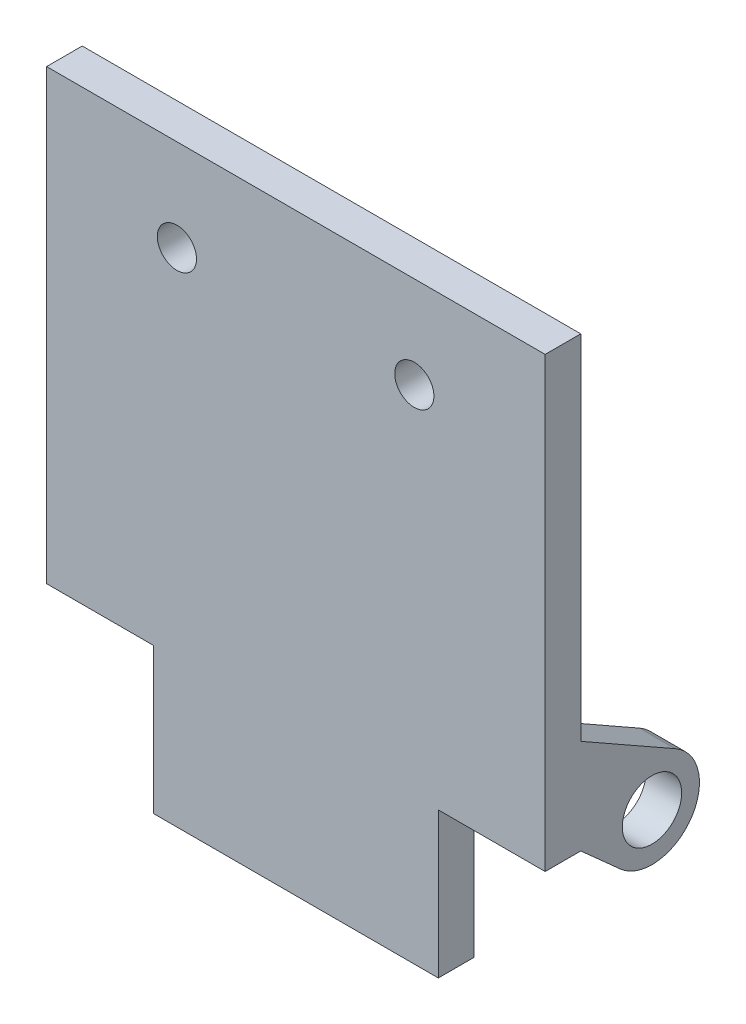
from build123d import *

# Parameters (mm, degrees)
SKETCH_1_W          = 42
SKETCH_1_H          = 50
EXTRUDE_1_DEPTH     = 3
SKETCH_3_W          = 3
SKETCH_3_H          = 5
SKETCH_3_H_2        = 10
EXTRUDE_2_DEPTH     = 12
FILLET_1_R          = 5
FILLET_2_R          = 5
SKETCH_4_R          = 1
CUT_EXTRUDE_1_DEPTH = 27
SKETCH_5_R          = 2.5
EXTRUDE_3_DEPTH     = 3
SKETCH_6_W          = 9
SKETCH_6_H          = 12.266046359
CUT_EXTRUDE_2_DEPTH = 4
SKETCH_7_R          = 1.65
CUT_EXTRUDE_3_DEPTH = 16
FILLET_3_R          = 3


with BuildPart() as part:
    # 草图1 → 凸台-拉伸1 (new body)
    with BuildSketch(Plane.XY):
        Rectangle(SKETCH_1_W, SKETCH_1_H)
    extrude(amount=EXTRUDE_1_DEPTH)

    # 草图3 → 凸台-拉伸2 (add)
    with BuildSketch(Plane(origin=(0, 0, 0), x_dir=(-1, 0, 0), z_dir=(0, 0, -1))):
        with Locations((3.5, -22.5)):
            Rectangle(SKETCH_3_W, SKETCH_3_H)
        with Locations((3.5, 8)):
            Rectangle(SKETCH_3_W, SKETCH_3_H_2)
    extrude(amount=EXTRUDE_2_DEPTH)

    # 圆角1
    fillet_1_edges = [part.edges().sort_by_distance(p)[0] for p in [
        (-2, 8, 0),
    ]]
    fillet(fillet_1_edges, radius=FILLET_1_R)

    # 圆角2
    fillet_2_edges = [part.edges().sort_by_distance(p)[0] for p in [
        (-2, -22.5, 0),
    ]]
    fillet(fillet_2_edges, radius=FILLET_2_R)

    # 草图4 → 切除-拉伸1 (cut, through all)
    with BuildSketch(Plane.ZY.offset(5)):
        with Locations((-5.946968178, -22)):
            Circle(SKETCH_4_R)
        with Locations((-5.946968178, 5)):
            Circle(SKETCH_4_R)
    extrude(amount=-CUT_EXTRUDE_1_DEPTH, mode=Mode.SUBTRACT)

    # 草图5 → 凸台-拉伸3 (add)
    with BuildSketch(Plane(origin=(21, 0, 0), x_dir=(0, 0, -1), z_dir=(1, 0, 0))):
        with BuildLine():
            Line((0, -4.733953641), (0, -12.733953641))
            Line((0, -12.733953641), (3.333333333, -15.715377611))
            ThreePointArc((3.333333333, -15.715377611), (9.249103106, -15.067047939), (7.972848445, -9.254317307))
            Line((7.972848445, -9.254317307), (0, -4.733953641))
        make_face()
        with Locations((6, -12.733953641)):
            Circle(SKETCH_5_R, mode=Mode.SUBTRACT)
    extrude(amount=-EXTRUDE_3_DEPTH)

    # 草图6 → 切除-拉伸2 (cut, through all)
    with BuildSketch(Plane(origin=(0, 0, 0), x_dir=(-1, 0, 0), z_dir=(0, 0, -1))):
        with Locations((-16.5, -18.86697682)):
            Rectangle(SKETCH_6_W, SKETCH_6_H)
        with Locations((16.5, -18.86697682)):
            Rectangle(SKETCH_6_W, SKETCH_6_H)
    extrude(amount=-CUT_EXTRUDE_2_DEPTH, mode=Mode.SUBTRACT)

    # 草图7 → 切除-拉伸3 (cut, through all)
    with BuildSketch(Plane.XY.offset(3)):
        with Locations((9.975799492, 17.266046359)):
            Circle(SKETCH_7_R)
        with Locations((-10.024200508, 17.266046359)):
            Circle(SKETCH_7_R)
    extrude(amount=-CUT_EXTRUDE_3_DEPTH, mode=Mode.SUBTRACT)

    # 圆角3
    fillet_3_edges = [part.edges().sort_by_distance(p)[0] for p in [
        (-3.5, -25, -12),
    ]]
    fillet(fillet_3_edges, radius=FILLET_3_R)


solid = part.part
